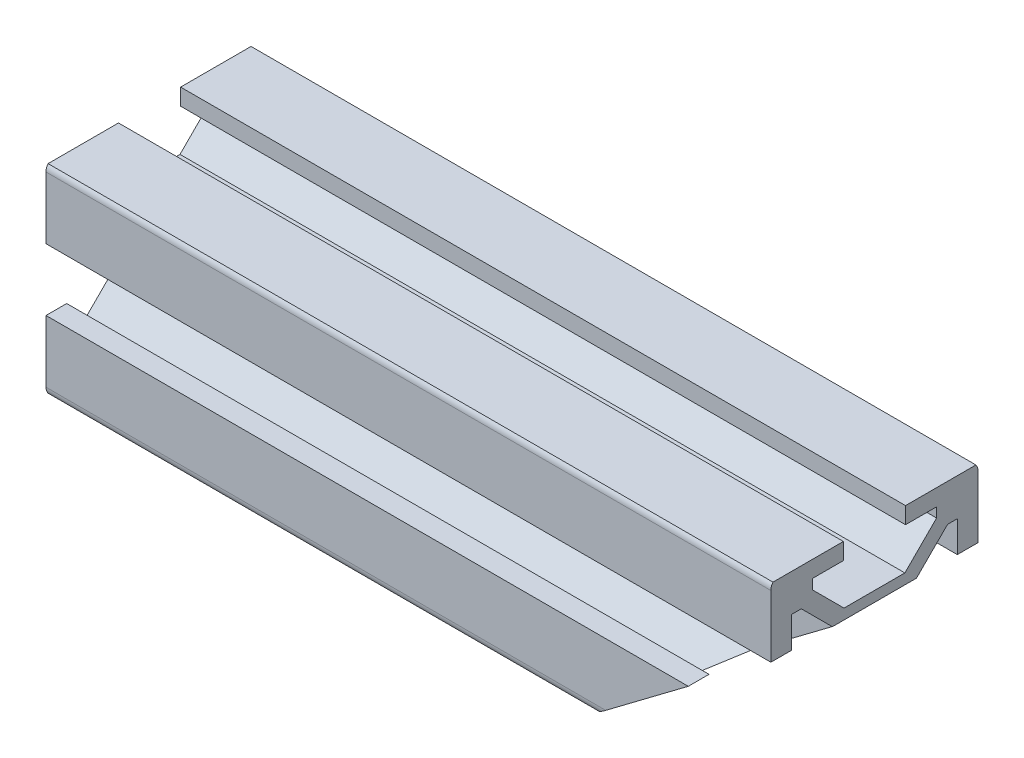
from build123d import *

# Parameters (mm, degrees)
SKETCH1_R                = 2.1
BOSS_EXTRUDE1_DEPTH      = 70
CUT_EXTRUDE_1_DEPTH      = 1
CUT_EXTRUDE_1_DEPTH_BACK = 21


with BuildPart() as part:
    # Sketch1 → Boss-Extrude1 (new body)
    with BuildSketch(Plane(origin=(0, 0, 0), x_dir=(0, 0, -1), z_dir=(1, 0, 0))):
        with BuildLine():
            Line((-10, 9), (-10, 3))
            Line((-10, 3), (-8, 3))
            Line((-8, 3), (-8, 6))
            Line((-8, 6), (-7.060660172, 6))
            Line((-7.060660172, 6), (-4, 2.939339828))
            Line((-4, 2.939339828), (-4, -2.939339828))
            Line((-4, -2.939339828), (-7.060660172, -6))
            Line((-7.060660172, -6), (-8, -6))
            Line((-8, -6), (-8, -3))
            Line((-8, -3), (-10, -3))
            Line((-10, -3), (-10, -9))
            ThreePointArc((-10, -9), (-9.948683298, -9.316227766), (-9.8, -9.6))
            Line((-9.8, -9.6), (-3, -9.6))
            Line((-3, -9.6), (-3, -8))
            Line((-3, -8), (-6, -8))
            Line((-6, -8), (-6, -7.060660172))
            Line((-6, -7.060660172), (-2.939339828, -4))
            Line((-2.939339828, -4), (2.939339828, -4))
            Line((2.939339828, -4), (6, -7.060660172))
            Line((6, -7.060660172), (6, -8))
            Line((6, -8), (3, -8))
            Line((3, -8), (3, -9.6))
            Line((3, -9.6), (9.8, -9.6))
            ThreePointArc((9.8, -9.6), (9.948683298, -9.316227766), (10, -9))
            Line((10, -9), (10, -3))
            Line((10, -3), (8, -3))
            Line((8, -3), (8, -6))
            Line((8, -6), (7.060660172, -6))
            Line((7.060660172, -6), (4, -2.939339828))
            Line((4, -2.939339828), (4, 2.939339828))
            Line((4, 2.939339828), (7.060660172, 6))
            Line((7.060660172, 6), (8, 6))
            Line((8, 6), (8, 3))
            Line((8, 3), (10, 3))
            Line((10, 3), (10, 9))
            ThreePointArc((10, 9), (9.948683298, 9.316227766), (9.8, 9.6))
            Line((9.8, 9.6), (3, 9.6))
            Line((3, 9.6), (3, 8))
            Line((3, 8), (6, 8))
            Line((6, 8), (6, 7.060660172))
            Line((6, 7.060660172), (2.939339828, 4))
            Line((2.939339828, 4), (-2.939339828, 4))
            Line((-2.939339828, 4), (-6, 7.060660172))
            Line((-6, 7.060660172), (-6, 8))
            Line((-6, 8), (-3, 8))
            Line((-3, 8), (-3, 9.6))
            Line((-3, 9.6), (-9.8, 9.6))
            ThreePointArc((-9.8, 9.6), (-9.948683298, 9.316227766), (-10, 9))
        make_face()
        Circle(SKETCH1_R, mode=Mode.SUBTRACT)
    extrude(amount=BOSS_EXTRUDE1_DEPTH)

    # 草图1 → 切除-拉伸1 (cut, two sides)
    with BuildSketch(Plane.XY.offset(10)) as cut_extrude_1_sk:
        Polygon((53.252194875, -9.6), (70, 3), (72.108704706, -2.849693058), (72.521016137, -11.388110896), align=None)
    extrude(amount=CUT_EXTRUDE_1_DEPTH, mode=Mode.SUBTRACT)
    extrude(cut_extrude_1_sk.sketch, amount=-CUT_EXTRUDE_1_DEPTH_BACK, mode=Mode.SUBTRACT)


solid = part.part
